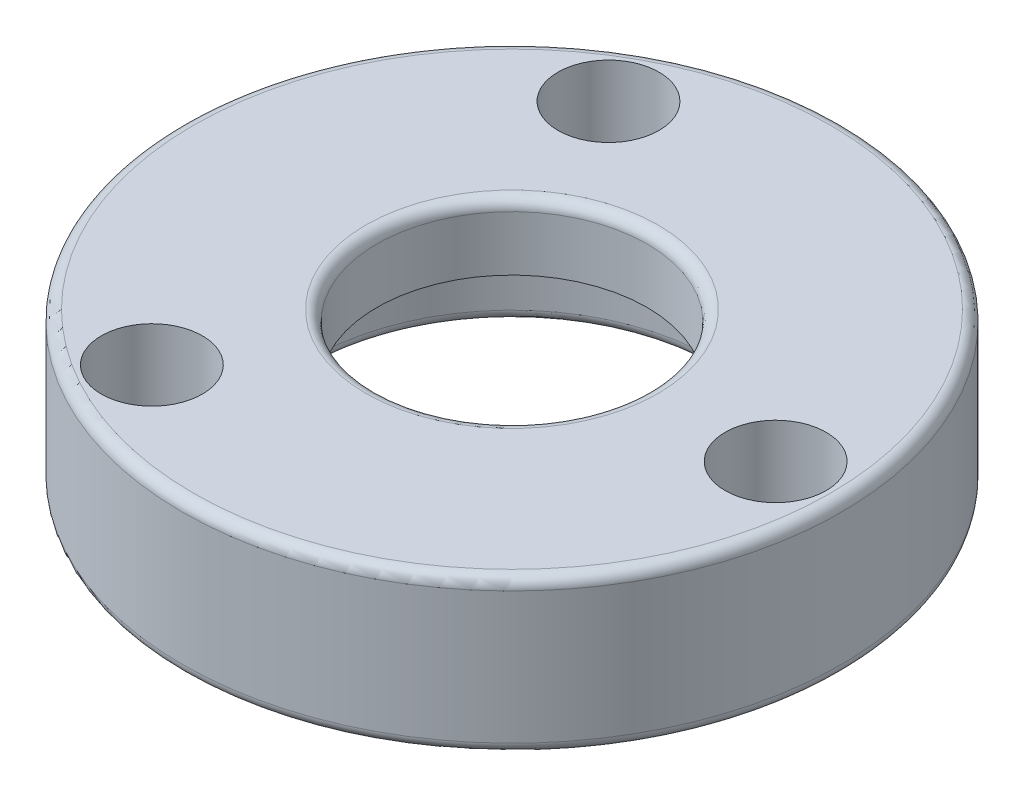
from build123d import *

# Parameters (mm, degrees)
SKETCH2_R          = 1.15
CUT_EXTRUDE1_DEPTH = 10
FILLET3_R          = 0.25
FILLET4_R          = 0.25
FILLET5_R          = 0.25


with BuildPart() as part:
    # Sketch1 → Revolve1 (revolve)
    with BuildSketch(Plane.XY):
        Polygon((-4.572, 0), (-7.5, 0), (-7.5, 3.5), (-3.0734, 3.5), (-3.0734, 2), (-4.572, 2), align=None)
    revolve(axis=Axis((0, 0, 0), (0, 1, 0)))

    # Sketch2 → Cut-Extrude1 (cut)
    with BuildSketch(Plane(origin=(0, 3.5, 0), x_dir=(1, 0, 0), z_dir=(0, 1, 0))):
        with Locations((6, 0)):
            Circle(SKETCH2_R)
        with Locations((-3, -5.196152423)):
            Circle(SKETCH2_R)
        with Locations((-3, 5.196152423)):
            Circle(SKETCH2_R)
    extrude(amount=-CUT_EXTRUDE1_DEPTH, mode=Mode.SUBTRACT)

    # Fillet3
    fillet3_edges = [part.edges().sort_by_distance(p)[0] for p in [
        (3.0734, 3.5, 0),
    ]]
    fillet(fillet3_edges, radius=FILLET3_R)

    # Fillet4
    fillet4_edges = [part.edges().sort_by_distance(p)[0] for p in [
        (7.5, 3.5, 0),
    ]]
    fillet(fillet4_edges, radius=FILLET4_R)

    # Fillet5
    fillet5_edges = [part.edges().sort_by_distance(p)[0] for p in [
        (7.5, 0, 0),
        (4.572, 0, 0),
    ]]
    fillet(fillet5_edges, radius=FILLET5_R)


solid = part.part
